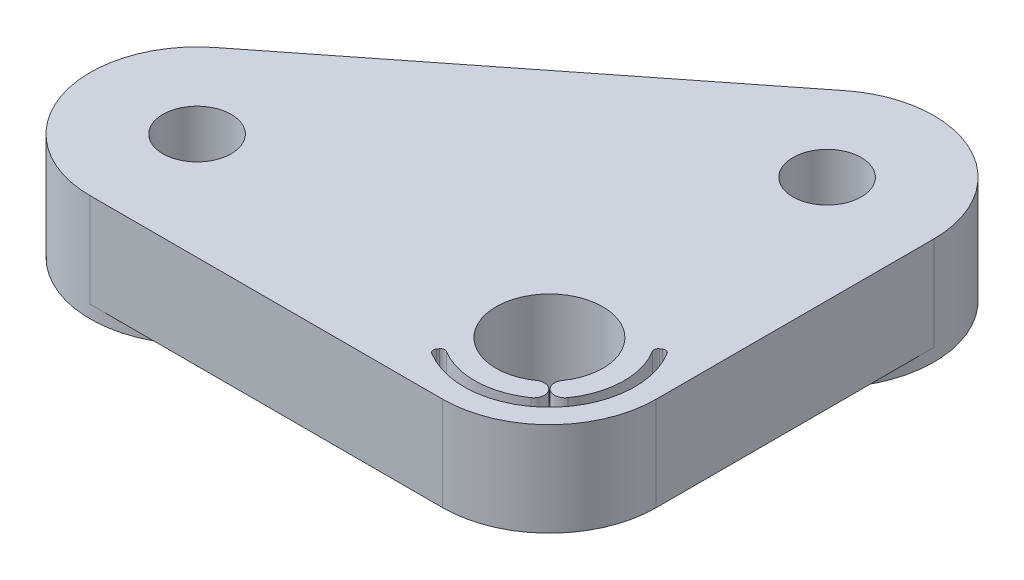
from build123d import *
from build123d.topology import SkipClean

# Parameters (mm, degrees)
SKETCH1_R            = 1.6
SKETCH1_R_2          = 2.5
BOSS_EXTRUDE1_DEPTH  = 1.57
FILLET1_R            = 5
SKETCH2_R            = 2.5
SKETCH2_R_2          = 1.6
BOSS_EXTRUDE2_DEPTH  = 2.83
SKETCH3_R            = 5
SKETCH3_R_2          = 1.6
BOSS_EXTRUDE3_DEPTH  = 0.6
CUT_EXTRUDE1_DEPTH   = 10
SKETCH6_W            = 1.221153847
SKETCH6_H            = 0.325641026
PART_NUM_RIGHT_DEPTH = 0.4


with BuildPart() as part:
    # Sketch1 → Boss-Extrude1 (new body)
    with BuildSketch(Plane(origin=(0, 0, 0), x_dir=(1, 0, 0), z_dir=(0, 1, 0))):
        Polygon((-5, -5), (30.925365976, -5), (-5, 23.304833799), align=None)
        with Locations(Location((16.5, 0, 0), (0, 0, 270))):
            Circle(SKETCH1_R, mode=Mode.SUBTRACT)
        with Locations(Location((0, 0, 0), (0, 0, 270))):
            Circle(SKETCH1_R_2, mode=Mode.SUBTRACT)
        with Locations(Location((0, 13, 0), (0, 0, 270))):
            Circle(SKETCH1_R, mode=Mode.SUBTRACT)
    extrude(amount=BOSS_EXTRUDE1_DEPTH)

    # Fillet1
    fillet1_edges = [part.edges().sort_by_distance(p)[0] for p in [
        (-5, 0.785, -23.304833799),
        (30.925365976, 0.785, 5),
        (-5, 0.785, 5),
    ]]
    fillet(fillet1_edges, radius=FILLET1_R)

    # Sketch2 → Boss-Extrude2 (add)
    with BuildSketch(Plane(origin=(0, 1.57, 0), x_dir=(1, 0, 0), z_dir=(0, 1, 0))):
        with BuildLine():
            Line((19.594361133, 3.927458361), (3.094361133, 16.927458361))
            ThreePointArc((3.094361133, 16.927458361), (-2.182681188, 17.498433375), (-5, 13))
            Line((-5, 13), (-5, 0))
            ThreePointArc((-5, 0), (-3.535533906, -3.535533906), (0, -5))
            Line((0, -5), (16.5, -5))
            ThreePointArc((16.5, -5), (21.224261413, -1.637484075), (19.594361133, 3.927458361))
        make_face()
        with Locations(Location((0, 0, 0), (0, 0, 270))):
            Circle(SKETCH2_R, mode=Mode.SUBTRACT)
        with Locations(Location((16.5, 0, 0), (0, 0, 270))):
            Circle(SKETCH2_R_2, mode=Mode.SUBTRACT)
        with Locations(Location((0, 13, 0), (0, 0, 270))):
            Circle(SKETCH2_R_2, mode=Mode.SUBTRACT)
    extrude(amount=BOSS_EXTRUDE2_DEPTH)

    # Sketch3 → Boss-Extrude3 (add)
    with BuildSketch(Plane.XZ):
        with Locations(Location((16.5, 0, 0), (0, 0, 270))):
            Circle(SKETCH3_R)
        with Locations(Location((16.5, 0, 0), (0, 0, 270))):
            Circle(SKETCH3_R_2, mode=Mode.SUBTRACT)
        with Locations(Location((0, -13, 0), (0, 0, 270))):
            Circle(SKETCH3_R)
        with Locations(Location((0, -13, 0), (0, 0, 270))):
            Circle(SKETCH3_R_2, mode=Mode.SUBTRACT)
    extrude(amount=BOSS_EXTRUDE3_DEPTH)

    # Sketch4 → Cut-Extrude1 (cut)
    with BuildSketch(Plane(origin=(0, 4.4, 0), x_dir=(1, 0, 0), z_dir=(0, 1, 0))):
        with BuildLine():
            Line((2.119130133, -3.026431476), (2.176569541, -3.108463452))
            ThreePointArc((2.176569541, -3.108463452), (2.208718169, -3.263081334), (2.118672771, -3.392819725))
            ThreePointArc((2.118672771, -3.392819725), (-2.828427125, -2.828427125), (-3.392819725, 2.118672771))
            ThreePointArc((-3.392819725, 2.118672771), (-3.263081334, 2.208718169), (-3.108463452, 2.176569541))
            Line((-3.108463452, 2.176569541), (-3.026431476, 2.119130133))
            ThreePointArc((-3.026431476, 2.119130133), (-2.945196197, 1.995341896), (-2.971355046, 1.849607847))
            ThreePointArc((-2.971355046, 1.849607847), (-3.498720526, -0.094629188), (-2.867032155, -2.007517527))
            ThreePointArc((-2.867032155, -2.007517527), (-2.170667915, -2.130305331), (-2.047880111, -1.433941091))
            ThreePointArc((-2.047880111, -1.433941091), (-1.767766953, -1.767766953), (-1.433941091, -2.047880111))
            ThreePointArc((-1.433941091, -2.047880111), (-2.130305331, -2.170667915), (-2.007517527, -2.867032155))
            ThreePointArc((-2.007517527, -2.867032155), (-0.094629188, -3.498720526), (1.849607847, -2.971355046))
            ThreePointArc((1.849607847, -2.971355046), (1.995341896, -2.945196197), (2.119130133, -3.026431476))
        make_face()
    extrude(amount=-CUT_EXTRUDE1_DEPTH, mode=Mode.SUBTRACT)


with BuildPart() as body_2:
    # Mirror1: mirrored copy
    add(part.part.mirror(Plane(origin=(-5, 1.57, -23.304833799), x_dir=(0, 0, 1), z_dir=(1, 0, 0))))

    # Sketch6 → Part Num Right (cut)
    with SkipClean():  # the faces are left unmerged after this step: merging them gives an invalid solid
        with BuildSketch(Plane(origin=(-13.243936204, 0, -16.809611336), x_dir=(-0.7854916722275357, 0, 0.6188722266035127), z_dir=(-0.6188722266035127, 0, -0.7854916722275357))):
            with BuildLine():
                Line((3.067040725, 3.775), (3.702422335, 3.775))
                add(Edge.make_bspline(
                    [(3.702422335, 3.775), (3.744823216, 3.774858861), (3.826237604, 3.774587859), (3.942871928, 3.773076774), (4.048850795, 3.768745752), (4.144118792, 3.76501868), (4.228674172, 3.758222418), (4.302776214, 3.751726689), (4.366083625, 3.743223439), (4.404406648, 3.735326377), (4.421758273, 3.731750801)],
                    knots=[0, 0, 0, 0, 1.410062039, 2.707475311, 3.878576406, 4.937260626, 5.877586885, 6.699081471, 7.410979367, 8, 8, 8, 8], degree=3))
                add(Edge.make_bspline(
                    [(4.421758273, 3.731750801), (4.444987139, 3.726011521), (4.490949337, 3.714655396), (4.557125468, 3.690652758), (4.62018489, 3.662876384), (4.67986566, 3.630252152), (4.735868842, 3.592537888), (4.788771881, 3.550384662), (4.838814837, 3.504023126), (4.883973887, 3.452284377), (4.926554312, 3.398004114), (4.962466852, 3.339308563), (4.993424444, 3.277929892), (5.018071985, 3.213243877), (5.037918432, 3.145877841), (5.051912235, 3.075221576), (5.060304384, 3.001596977), (5.061158781, 2.951379445), (5.061592007, 2.925916466)],
                    knots=[0, 0, 0, 0, 1.027469482, 2.033020251, 3.019912614, 3.986113645, 4.951240523, 5.91722682, 6.890402269, 7.87763091, 8.8651537, 9.85103654, 10.82876324, 11.815024772, 12.821070561, 13.842952187, 14.906261191, 16, 16, 16, 16], degree=3))
                add(Edge.make_bspline(
                    [(5.061592007, 2.925916466), (5.060259416, 2.883611764), (5.057659185, 2.801064333), (5.033415698, 2.681266248), (4.993704141, 2.569515941), (4.9389823, 2.46595412), (4.869296062, 2.372599463), (4.785544287, 2.290602407), (4.687680254, 2.221986201), (4.596576517, 2.174404013), (4.516100064, 2.143930446), (4.449848416, 2.122488892), (4.377579087, 2.105922681), (4.299984505, 2.091081704), (4.21674176, 2.079876953), (4.128050367, 2.071670399), (4.033847072, 2.066541369), (3.969132345, 2.065777551), (3.935840805, 2.065384615)],
                    knots=[0, 0, 0, 0, 1.260483769, 2.459530307, 3.627416485, 4.787058657, 5.939039949, 7.08810263, 8.267026773, 9.491475466, 10.141966685, 10.831826277, 11.566392101, 12.351337768, 13.187381173, 14.07005841, 15.007169909, 16, 16, 16, 16], degree=3))
                Line((3.935840805, 2.065384615), (5.102297135, 0.6))
                Line((5.102297135, 0.6), (4.749943369, 0.6))
                Line((4.749943369, 0.6), (3.583487039, 2.065384615))
                Line((3.583487039, 2.065384615), (3.351976622, 2.065384615))
                Line((3.351976622, 2.065384615), (3.351976622, 0.6))
                Line((3.351976622, 0.6), (3.067040725, 0.6))
                Line((3.067040725, 0.6), (3.067040725, 3.775))
            make_face()
            with BuildLine():
                Line((3.351976622, 3.449358974), (3.351976622, 2.391025641))
                Line((3.351976622, 2.391025641), (3.933296734, 2.386573518))
                add(Edge.make_bspline(
                    [(3.933296734, 2.386573518), (3.960438484, 2.38656151), (4.013046925, 2.386538236), (4.089156814, 2.390161162), (4.160022915, 2.3942826), (4.225374169, 2.40058665), (4.285239769, 2.408711086), (4.339589794, 2.418873793), (4.388512963, 2.430713879), (4.445570923, 2.449039639), (4.50928549, 2.47807367), (4.578529029, 2.520315229), (4.637495435, 2.573445788), (4.687313782, 2.63420028), (4.72734548, 2.700998877), (4.755568558, 2.773040869), (4.773477774, 2.848507533), (4.775590097, 2.900376245), (4.776656109, 2.926552484)],
                    knots=[0, 0, 0, 0, 1.146690395, 2.22261258, 3.21895312, 4.145990853, 4.996080663, 5.770904154, 6.481378293, 7.121626537, 8.300444488, 9.431385265, 10.535395872, 11.636531494, 12.74115979, 13.810798291, 14.895190096, 16, 16, 16, 16], degree=3))
                add(Edge.make_bspline(
                    [(4.776656109, 2.926552484), (4.775565614, 2.952085447), (4.773404649, 3.002682464), (4.755761838, 3.07675604), (4.725926471, 3.146666773), (4.685719869, 3.21213027), (4.636734921, 3.27155333), (4.57929662, 3.322396105), (4.514975479, 3.364350976), (4.454858034, 3.391161022), (4.401124142, 3.407598317), (4.354470093, 3.419165444), (4.301754681, 3.428458641), (4.242721943, 3.435904525), (4.177623893, 3.442304367), (4.106131373, 3.446614909), (4.028718723, 3.449167486), (3.975064007, 3.449293659), (3.947289122, 3.449358974)],
                    knots=[0, 0, 0, 0, 1.101028733, 2.181837193, 3.264309656, 4.369019818, 5.486613113, 6.575447106, 7.666700264, 8.788928104, 9.402425223, 10.0903467, 10.862060571, 11.710948788, 12.657782767, 13.684531032, 14.801375019, 16, 16, 16, 16], degree=3))
                Line((3.947289122, 3.449358974), (3.351976622, 3.449358974))
            make_face(mode=Mode.SUBTRACT)
            with BuildLine():
                Line((8.684348417, 3.192407853), (8.435029507, 3.001602564))
                add(Edge.make_bspline(
                    [(8.435029507, 3.001602564), (8.417244165, 3.022798837), (8.381913267, 3.06490561), (8.325072419, 3.124032768), (8.2658345, 3.179427684), (8.204222154, 3.231354246), (8.139126382, 3.277996598), (8.072124086, 3.321785384), (8.002094431, 3.361035404), (7.905255357, 3.408626827), (7.778574809, 3.45828941), (7.619103776, 3.499930199), (7.452632994, 3.52643798), (7.339060886, 3.529308943), (7.281293529, 3.530769231)],
                    knots=[0, 0, 0, 0, 0.757959112, 1.505699292, 2.245454638, 2.979532153, 3.711538275, 4.438200793, 5.171680507, 5.909471876, 7.393775596, 8.890124382, 10.418191784, 12, 12, 12, 12], degree=3))
                add(Edge.make_bspline(
                    [(7.281293529, 3.530769231), (7.249467965, 3.530402779), (7.186112207, 3.529673277), (7.092088235, 3.520049285), (6.999819967, 3.506522687), (6.909367423, 3.486451858), (6.820845739, 3.461076696), (6.733676203, 3.430755071), (6.649120873, 3.393240323), (6.566010043, 3.351776402), (6.486381758, 3.304942934), (6.411038965, 3.253858679), (6.340256451, 3.199095284), (6.273978224, 3.140447495), (6.212136528, 3.078179431), (6.155179468, 3.011627492), (6.103304131, 2.941004449), (6.055482259, 2.867241573), (6.012653565, 2.790553719), (5.976794317, 2.710657048), (5.945039671, 2.628919754), (5.919912501, 2.544418344), (5.900023832, 2.457747406), (5.88630088, 2.368674334), (5.876786338, 2.277385211), (5.876060463, 2.21550962), (5.875694571, 2.184319912)],
                    knots=[0, 0, 0, 0, 1.054917814, 2.100044995, 3.131103042, 4.146048494, 5.169673617, 6.183595914, 7.203665975, 8.234915748, 9.262203917, 10.264457458, 11.251630812, 12.227803204, 13.197192746, 14.159520551, 15.12972552, 16.100847026, 17.073214652, 18.039054194, 19.002613845, 19.979014051, 20.95965708, 21.949030935, 22.966165397, 24, 24, 24, 24], degree=3))
                add(Edge.make_bspline(
                    [(5.875694571, 2.184319912), (5.876839221, 2.137392215), (5.87908659, 2.045255905), (5.899087578, 1.910299709), (5.929481483, 1.781013097), (5.975034185, 1.658204241), (6.031203609, 1.540358801), (6.102179021, 1.429470699), (6.184381166, 1.323864244), (6.27897296, 1.226035284), (6.382755379, 1.136669262), (6.49410527, 1.057974091), (6.612745303, 0.992374162), (6.737365532, 0.937785982), (6.868924935, 0.895824522), (7.007186934, 0.86628421), (7.151850816, 0.847014518), (7.250701628, 0.845169672), (7.301010076, 0.844230769)],
                    knots=[0, 0, 0, 0, 1.029171465, 2.020641659, 2.987623507, 3.938342917, 4.889210282, 5.84687017, 6.821220943, 7.821438502, 8.827599549, 9.822697543, 10.807740252, 11.797342354, 12.80366471, 13.83203677, 14.896651826, 16, 16, 16, 16], degree=3))
                add(Edge.make_bspline(
                    [(7.301010076, 0.844230769), (7.356438944, 0.845762734), (7.465536215, 0.848778006), (7.625527211, 0.874322468), (7.778685369, 0.915740722), (7.92501893, 0.973705266), (8.064115359, 1.049057348), (8.196192329, 1.140404709), (8.321361326, 1.248616268), (8.396628132, 1.331241677), (8.435029507, 1.373397436)],
                    knots=[0, 0, 0, 0, 1.028121516, 2.023589091, 2.998037872, 3.967518031, 4.937445131, 5.927275754, 6.942489185, 8, 8, 8, 8], degree=3))
                Line((8.435029507, 1.373397436), (8.684348417, 1.1845002))
                add(Edge.make_bspline(
                    [(8.684348417, 1.1845002), (8.664284132, 1.158611748), (8.624251668, 1.106958846), (8.559429038, 1.034140938), (8.491141775, 0.965647992), (8.418882667, 0.902032221), (8.343482956, 0.84202067), (8.263588787, 0.787318294), (8.18025045, 0.737161564), (8.093750316, 0.691235711), (8.004180289, 0.650489351), (7.911647694, 0.61560629), (7.816551386, 0.585557283), (7.718887018, 0.560835883), (7.61845201, 0.541539972), (7.515608794, 0.528640695), (7.410135407, 0.519803387), (7.338977832, 0.518997921), (7.302918129, 0.518589744)],
                    knots=[0, 0, 0, 0, 0.986787822, 1.968848986, 2.935600012, 3.899624008, 4.868462664, 5.837806735, 6.815139263, 7.798259679, 8.787526145, 9.778297419, 10.776456485, 11.791383307, 12.812564526, 13.85620153, 14.913611965, 16, 16, 16, 16], degree=3))
                add(Edge.make_bspline(
                    [(7.302918129, 0.518589744), (7.268769945, 0.518827408), (7.20124614, 0.519297361), (7.101552273, 0.526910255), (7.004497439, 0.537296803), (6.910359028, 0.552936064), (6.818623322, 0.571391287), (6.730121935, 0.596130213), (6.643983994, 0.623842671), (6.560555571, 0.656413623), (6.4797657, 0.693167589), (6.401874957, 0.734707074), (6.326919165, 0.780682766), (6.25416139, 0.83008124), (6.184676439, 0.884489221), (6.11786217, 0.943151096), (6.053343923, 1.005869149), (6.013427202, 1.051094623), (5.993357832, 1.073833133)],
                    knots=[0, 0, 0, 0, 1.114604814, 2.203992996, 3.262667896, 4.300477797, 5.318619304, 6.316056647, 7.298880507, 8.271930387, 9.238335007, 10.195173496, 11.151986948, 12.108099108, 13.064862484, 14.031167946, 15.010108607, 16, 16, 16, 16], degree=3))
                add(Edge.make_bspline(
                    [(5.993357832, 1.073833133), (5.961212641, 1.113331212), (5.897310344, 1.191850513), (5.815553474, 1.319109939), (5.745569621, 1.451977528), (5.68898575, 1.591151321), (5.644750985, 1.736319022), (5.614106615, 1.88755381), (5.594193374, 2.044714444), (5.591916183, 2.151609245), (5.590758673, 2.205944511)],
                    knots=[0, 0, 0, 0, 0.994628077, 1.977248131, 2.950237994, 3.925870899, 4.908910175, 5.911660606, 6.938484602, 8, 8, 8, 8], degree=3))
                add(Edge.make_bspline(
                    [(5.590758673, 2.205944511), (5.592169456, 2.263054101), (5.594945083, 2.375413654), (5.618526983, 2.540308598), (5.656462606, 2.698288795), (5.710344069, 2.849059335), (5.77865678, 2.993413232), (5.863045209, 3.130247753), (5.962528973, 3.260437993), (6.076327838, 3.382008518), (6.201121064, 3.493169216), (6.334760274, 3.590964844), (6.476983897, 3.672351447), (6.626225091, 3.74038368), (6.783601388, 3.792675443), (6.948777016, 3.829281549), (7.121441602, 3.852066361), (7.239245374, 3.854946728), (7.299102023, 3.856410256)],
                    knots=[0, 0, 0, 0, 1.032925535, 2.032216505, 3.007276963, 3.968222605, 4.92396291, 5.891752235, 6.871517503, 7.883894988, 8.900124299, 9.891468569, 10.874487609, 11.85992873, 12.854644235, 13.869047385, 14.917252991, 16, 16, 16, 16], degree=3))
                add(Edge.make_bspline(
                    [(7.299102023, 3.856410256), (7.335582294, 3.855972888), (7.407791316, 3.855107162), (7.514609794, 3.846665162), (7.618606762, 3.832592104), (7.719853867, 3.813436813), (7.818843669, 3.789663028), (7.914819602, 3.7586929), (8.008344839, 3.72328119), (8.098829534, 3.682497439), (8.185839548, 3.636716895), (8.269347779, 3.586447007), (8.348690901, 3.531750098), (8.424427214, 3.47309136), (8.495289777, 3.40922981), (8.563290546, 3.341921991), (8.626120239, 3.269229165), (8.664903494, 3.218061832), (8.684348417, 3.192407853)],
                    knots=[0, 0, 0, 0, 1.096760587, 2.17092713, 3.219439832, 4.250915756, 5.268269357, 6.278326846, 7.281116186, 8.274029601, 9.260640565, 10.235837813, 11.203064059, 12.156899882, 13.114053108, 14.069676657, 15.032185724, 16, 16, 16, 16], degree=3))
            make_face()
            with BuildLine():
                Line((9.335630468, 3.775), (9.971012079, 3.775))
                add(Edge.make_bspline(
                    [(9.971012079, 3.775), (10.01341296, 3.774858861), (10.094827348, 3.774587859), (10.211461672, 3.773076774), (10.317440538, 3.768745752), (10.412708535, 3.76501868), (10.497263915, 3.758222418), (10.571365958, 3.751726689), (10.634673369, 3.743223439), (10.672996391, 3.735326377), (10.690348016, 3.731750801)],
                    knots=[0, 0, 0, 0, 1.410062039, 2.707475311, 3.878576406, 4.937260626, 5.877586885, 6.699081471, 7.410979367, 8, 8, 8, 8], degree=3))
                add(Edge.make_bspline(
                    [(10.690348016, 3.731750801), (10.713576883, 3.726011521), (10.75953908, 3.714655396), (10.825715211, 3.690652758), (10.888774634, 3.662876384), (10.948455403, 3.630252152), (11.004458585, 3.592537888), (11.057361624, 3.550384662), (11.10740458, 3.504023126), (11.152563631, 3.452284377), (11.195144056, 3.398004114), (11.231056596, 3.339308563), (11.262014188, 3.277929892), (11.286661728, 3.213243877), (11.306508176, 3.145877841), (11.320501979, 3.075221576), (11.328894127, 3.001596977), (11.329748525, 2.951379445), (11.33018175, 2.925916466)],
                    knots=[0, 0, 0, 0, 1.027469482, 2.033020251, 3.019912614, 3.986113645, 4.951240523, 5.91722682, 6.890402269, 7.87763091, 8.8651537, 9.85103654, 10.82876324, 11.815024772, 12.821070561, 13.842952187, 14.906261191, 16, 16, 16, 16], degree=3))
                add(Edge.make_bspline(
                    [(11.33018175, 2.925916466), (11.328849159, 2.883611764), (11.326248929, 2.801064333), (11.302005442, 2.681266248), (11.262293885, 2.569515941), (11.207572044, 2.46595412), (11.137885805, 2.372599463), (11.05413403, 2.290602407), (10.956269997, 2.221986201), (10.865166261, 2.174404013), (10.784689808, 2.143930446), (10.71843816, 2.122488892), (10.64616883, 2.105922681), (10.568574248, 2.091081704), (10.485331504, 2.079876953), (10.396640111, 2.071670399), (10.302436816, 2.066541369), (10.237722089, 2.065777551), (10.204430548, 2.065384615)],
                    knots=[0, 0, 0, 0, 1.260483769, 2.459530307, 3.627416485, 4.787058657, 5.939039949, 7.08810263, 8.267026773, 9.491475466, 10.141966685, 10.831826277, 11.566392101, 12.351337768, 13.187381173, 14.07005841, 15.007169909, 16, 16, 16, 16], degree=3))
                Line((10.204430548, 2.065384615), (11.370886879, 0.6))
                Line((11.370886879, 0.6), (11.018533113, 0.6))
                Line((11.018533113, 0.6), (9.852076782, 2.065384615))
                Line((9.852076782, 2.065384615), (9.620566366, 2.065384615))
                Line((9.620566366, 2.065384615), (9.620566366, 0.6))
                Line((9.620566366, 0.6), (9.335630468, 0.6))
                Line((9.335630468, 0.6), (9.335630468, 3.775))
            make_face()
            with BuildLine():
                Line((9.620566366, 3.449358974), (9.620566366, 2.391025641))
                Line((9.620566366, 2.391025641), (10.201886478, 2.386573518))
                add(Edge.make_bspline(
                    [(10.201886478, 2.386573518), (10.229028228, 2.38656151), (10.281636669, 2.386538236), (10.357746557, 2.390161162), (10.428612659, 2.3942826), (10.493963912, 2.40058665), (10.553829513, 2.408711086), (10.608179538, 2.418873793), (10.657102706, 2.430713879), (10.714160666, 2.449039639), (10.777875234, 2.47807367), (10.847118772, 2.520315229), (10.906085179, 2.573445788), (10.955903525, 2.63420028), (10.995935224, 2.700998877), (11.024158302, 2.773040869), (11.042067517, 2.848507533), (11.044179841, 2.900376245), (11.045245853, 2.926552484)],
                    knots=[0, 0, 0, 0, 1.146690395, 2.22261258, 3.21895312, 4.145990853, 4.996080663, 5.770904154, 6.481378293, 7.121626537, 8.300444488, 9.431385265, 10.535395872, 11.636531494, 12.74115979, 13.810798291, 14.895190096, 16, 16, 16, 16], degree=3))
                add(Edge.make_bspline(
                    [(11.045245853, 2.926552484), (11.044155357, 2.952085447), (11.041994393, 3.002682464), (11.024351582, 3.07675604), (10.994516214, 3.146666773), (10.954309613, 3.21213027), (10.905324665, 3.27155333), (10.847886363, 3.322396105), (10.783565222, 3.364350976), (10.723447778, 3.391161022), (10.669713885, 3.407598317), (10.623059836, 3.419165444), (10.570344425, 3.428458641), (10.511311687, 3.435904525), (10.446213636, 3.442304367), (10.374721117, 3.446614909), (10.297308466, 3.449167486), (10.24365375, 3.449293659), (10.215878866, 3.449358974)],
                    knots=[0, 0, 0, 0, 1.101028733, 2.181837193, 3.264309656, 4.369019818, 5.486613113, 6.575447106, 7.666700264, 8.788928104, 9.402425223, 10.0903467, 10.862060571, 11.710948788, 12.657782767, 13.684531032, 14.801375019, 16, 16, 16, 16], degree=3))
                Line((10.215878866, 3.449358974), (9.620566366, 3.449358974))
            make_face(mode=Mode.SUBTRACT)
            with Locations((12.347809956, 1.821153846)):
                Rectangle(SKETCH6_W, SKETCH6_H)
            with BuildLine():
                add(Edge.make_bspline(
                    [(13.202617648, 2.186227965), (13.202915207, 2.237116309), (13.20349322, 2.335967652), (13.209923431, 2.480008006), (13.220605349, 2.615136268), (13.235244251, 2.741358907), (13.253058705, 2.858708507), (13.276839896, 2.966871466), (13.303884367, 3.066348394), (13.335228371, 3.157463681), (13.370595866, 3.241444883), (13.409089802, 3.319844887), (13.452237866, 3.392545069), (13.497574065, 3.460705779), (13.546933587, 3.523211273), (13.598911776, 3.58094426), (13.655537335, 3.632570441), (13.71488535, 3.679602444), (13.777493142, 3.720831607), (13.841576132, 3.75714702), (13.907575407, 3.788171185), (13.975671159, 3.812564652), (14.045251336, 3.832713063), (14.116559175, 3.846491609), (14.189712412, 3.85516109), (14.2390895, 3.855989917), (14.264131069, 3.856410256)],
                    knots=[0, 0, 0, 0, 1.646270934, 3.197905019, 4.663502075, 6.030701355, 7.308322542, 8.50163776, 9.611534131, 10.641858119, 11.616356847, 12.558055219, 13.465016945, 14.349605745, 15.204443733, 16.039544428, 16.859896111, 17.680448484, 18.487036065, 19.28249412, 20.06191084, 20.843045899, 21.620316918, 22.403196591, 23.190181807, 24, 24, 24, 24], degree=3))
                add(Edge.make_bspline(
                    [(14.264131069, 3.856410256), (14.289381825, 3.855967738), (14.339597633, 3.855087709), (14.413838545, 3.846629561), (14.486364327, 3.832595043), (14.556865782, 3.812709587), (14.625922019, 3.788039223), (14.692992904, 3.757117338), (14.758495042, 3.721122937), (14.821387517, 3.67882842), (14.882360775, 3.631673069), (14.939917142, 3.578366934), (14.994061855, 3.51944826), (15.045474454, 3.455547427), (15.092696317, 3.385438814), (15.137666502, 3.3103418), (15.177918277, 3.228943087), (15.216684733, 3.142600805), (15.250146499, 3.048925915), (15.280323736, 2.948446454), (15.3047068, 2.839975584), (15.325017069, 2.724082419), (15.340751367, 2.600341345), (15.352210978, 2.469017616), (15.35826442, 2.330024833), (15.359404427, 2.234994498), (15.359989443, 2.186227965)],
                    knots=[0, 0, 0, 0, 0.810914788, 1.612654377, 2.396697861, 3.181598691, 3.963628158, 4.749916497, 5.551656086, 6.361998678, 7.18212741, 8.025565596, 8.878627764, 9.750805457, 10.657531673, 11.591944965, 12.560506719, 13.57287815, 14.630710178, 15.753379473, 16.941251878, 18.199788006, 19.531962791, 20.947069417, 22.433333509, 24, 24, 24, 24], degree=3))
                add(Edge.make_bspline(
                    [(15.359989443, 2.186227965), (15.359398362, 2.137674134), (15.358246667, 2.043068975), (15.35227884, 1.90470159), (15.34052351, 1.774074794), (15.325818735, 1.650875303), (15.305452504, 1.535615891), (15.280410675, 1.427897713), (15.252606453, 1.327255591), (15.21828489, 1.234514012), (15.18071946, 1.148379235), (15.139847961, 1.067945464), (15.096060333, 0.992501756), (15.048354828, 0.922651986), (14.997506375, 0.857901347), (14.942426667, 0.799392789), (14.88466835, 0.745716537), (14.823515659, 0.697953989), (14.759642323, 0.656148487), (14.69436516, 0.618761637), (14.626525948, 0.588614835), (14.557662055, 0.562729477), (14.486788466, 0.542953353), (14.413993526, 0.529279212), (14.339647512, 0.519689035), (14.289390378, 0.518957443), (14.264131069, 0.518589744)],
                    knots=[0, 0, 0, 0, 1.561518951, 3.042555995, 4.452378317, 5.7783523, 7.031515105, 8.214008947, 9.334062868, 10.386615937, 11.391082383, 12.354592575, 13.286541444, 14.194233754, 15.072674879, 15.931287219, 16.775624067, 17.606195743, 18.42308326, 19.229000347, 20.022332153, 20.807536673, 21.593273796, 22.3848459, 23.188221202, 24, 24, 24, 24], degree=3))
                add(Edge.make_bspline(
                    [(14.264131069, 0.518589744), (14.239090194, 0.519012795), (14.189714477, 0.519846969), (14.116551205, 0.528477282), (14.045537846, 0.542352489), (13.976323976, 0.561780408), (13.908554495, 0.58556101), (13.843152863, 0.61654328), (13.779391893, 0.652224899), (13.717441696, 0.692860746), (13.658466378, 0.739416844), (13.602134072, 0.790910163), (13.549859947, 0.848625686), (13.501206161, 0.911652088), (13.454965381, 0.979409529), (13.412430021, 1.052823125), (13.37308646, 1.131601779), (13.337124151, 1.216254455), (13.305239292, 1.308016425), (13.277074585, 1.407937466), (13.254836742, 1.516899507), (13.235802204, 1.634027404), (13.220449371, 1.75982447), (13.209967947, 1.894358997), (13.203489754, 2.037547151), (13.202913655, 2.135763303), (13.202617648, 2.186227965)],
                    knots=[0, 0, 0, 0, 0.810891512, 1.598919785, 2.382837074, 3.152667961, 3.926044502, 4.706494248, 5.493654104, 6.291793342, 7.103789334, 7.925228297, 8.761435821, 9.622817696, 10.50288917, 11.416980706, 12.369136599, 13.353924996, 14.394355917, 15.514179734, 16.714354668, 17.994756427, 19.357759367, 20.818452758, 22.365282078, 24, 24, 24, 24], degree=3))
            make_face()
            with BuildLine():
                add(Edge.make_bspline(
                    [(13.487553545, 2.1875), (13.487661901, 2.145092252), (13.487872198, 2.06278714), (13.493366037, 1.943186467), (13.500850176, 1.831634812), (13.510503352, 1.727990532), (13.524838884, 1.63260445), (13.54090147, 1.544820523), (13.560448666, 1.465103315), (13.583576289, 1.392905801), (13.609918899, 1.327002717), (13.638680646, 1.265678758), (13.669578588, 1.208209501), (13.704158103, 1.155111156), (13.741818196, 1.106210565), (13.781708224, 1.06064221), (13.825316926, 1.020004948), (13.885645321, 0.971267015), (13.965289265, 0.92090323), (14.065637821, 0.87704642), (14.168751344, 0.849485191), (14.23873855, 0.845980213), (14.273671334, 0.844230769)],
                    knots=[0, 0, 0, 0, 1.459021318, 2.831673884, 4.118529203, 5.306027144, 6.411944654, 7.436330062, 8.375795394, 9.233974572, 10.042671642, 10.816086306, 11.563610507, 12.285937304, 12.993564865, 13.685989202, 14.367179055, 15.041617293, 16.353048772, 17.594441528, 18.799311195, 20, 20, 20, 20], degree=3))
                add(Edge.make_bspline(
                    [(14.273671334, 0.844230769), (14.308830079, 0.845680185), (14.379074979, 0.848576023), (14.481703493, 0.876514878), (14.581335238, 0.918669388), (14.659414784, 0.968514626), (14.718816806, 1.015983896), (14.761377218, 1.056455755), (14.800440648, 1.101772864), (14.837490244, 1.150667225), (14.871470977, 1.204072978), (14.902371109, 1.261733315), (14.930568146, 1.323808354), (14.94663278, 1.367142332), (14.954846213, 1.389297877)],
                    knots=[0, 0, 0, 0, 1.353760809, 2.704726607, 4.075137775, 5.516104923, 6.260822281, 7.007110065, 7.778089737, 8.566572457, 9.372053459, 10.217411131, 11.088608312, 12, 12, 12, 12], degree=3))
                add(Edge.make_bspline(
                    [(14.954846213, 1.389297877), (14.964418174, 1.417627712), (14.98385336, 1.475149426), (15.008901183, 1.564379311), (15.028627367, 1.657998961), (15.046374135, 1.755448888), (15.058487264, 1.85744776), (15.068237066, 1.96367998), (15.073979903, 2.074225644), (15.074691785, 2.149332529), (15.075053545, 2.1875)],
                    knots=[0, 0, 0, 0, 0.884706709, 1.796334032, 2.740027952, 3.714592787, 4.726048262, 5.777819803, 6.87074269, 8, 8, 8, 8], degree=3))
                add(Edge.make_bspline(
                    [(15.075053545, 2.1875), (15.074554445, 2.225661298), (15.073578098, 2.300312955), (15.069846124, 2.409640161), (15.060209024, 2.513478773), (15.049505538, 2.61227613), (15.033723773, 2.705485333), (15.016707762, 2.793886682), (14.993846662, 2.876384997), (14.969426581, 2.954271903), (14.941477151, 3.026662497), (14.910710735, 3.093894289), (14.877852425, 3.156291861), (14.842163392, 3.213684015), (14.804067309, 3.266327822), (14.762558675, 3.313167775), (14.719283994, 3.355655596), (14.658671261, 3.404153784), (14.579319584, 3.453603679), (14.480581032, 3.49911119), (14.377828376, 3.525244427), (14.308365314, 3.528928957), (14.273671334, 3.530769231)],
                    knots=[0, 0, 0, 0, 1.31362396, 2.569729283, 3.763502607, 4.902122613, 5.988968491, 7.01645872, 7.998833611, 8.933434873, 9.825090667, 10.667526885, 11.477055099, 12.250526234, 12.991942729, 13.710640831, 14.402115721, 15.076753259, 16.378508321, 17.609869233, 18.806226677, 20, 20, 20, 20], degree=3))
                add(Edge.make_bspline(
                    [(14.273671334, 3.530769231), (14.238555297, 3.528926418), (14.168259249, 3.525237437), (14.064438605, 3.499208557), (13.964921086, 3.453839652), (13.885779244, 3.40399), (13.825124238, 3.356511674), (13.782413509, 3.315339677), (13.742366624, 3.270303432), (13.705475211, 3.220953123), (13.670922789, 3.167916683), (13.639190014, 3.110776875), (13.610599293, 3.049244137), (13.584215464, 2.983370657), (13.561017292, 2.911179371), (13.541882054, 2.831560356), (13.524204513, 2.744055639), (13.511690233, 2.648152943), (13.500565255, 2.544482704), (13.493415746, 2.432652565), (13.48785382, 2.312851306), (13.487655641, 2.230120641), (13.487553545, 2.1875)],
                    knots=[0, 0, 0, 0, 1.207732386, 2.417664972, 3.655092373, 4.956220595, 5.625982001, 6.301752483, 6.994047911, 7.697131622, 8.419323945, 9.170223765, 9.943494443, 10.752040957, 11.610060368, 12.549350801, 13.567764191, 14.679664412, 15.874934091, 17.154273443, 18.533957287, 20, 20, 20, 20], degree=3))
            make_face(mode=Mode.SUBTRACT)
            Polygon((16.319740044, 3.775), (16.906784314, 3.775), (16.906784314, 0.6), (16.621848417, 0.6), (16.621848417, 3.449358974), (16.133386879, 3.449358974), align=None)
        extrude(amount=-PART_NUM_RIGHT_DEPTH, mode=Mode.SUBTRACT)


solid = body_2.part
